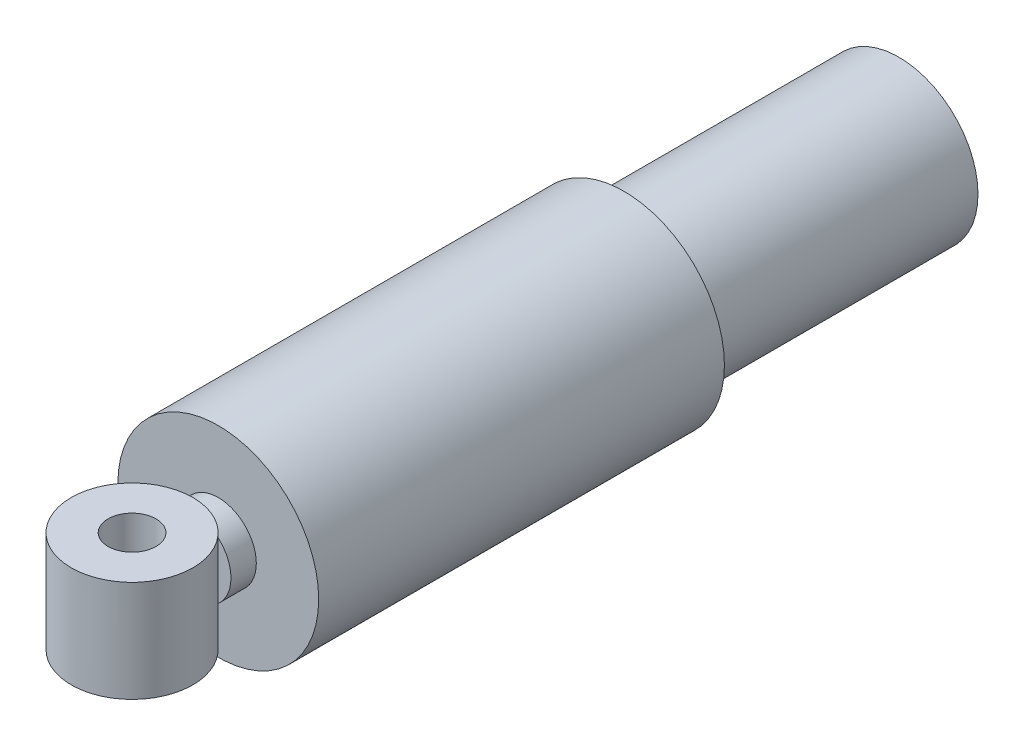
from build123d import *

# Parameters (mm, degrees)
SKETCH1_R           = 19.812
BOSS_EXTRUDE1_DEPTH = 68.834
SKETCH2_R           = 25.146
BOSS_EXTRUDE2_DEPTH = 101.6
SKETCH3_R           = 9.525
BOSS_EXTRUDE3_DEPTH = 6.35
SKETCH5_R           = 15.24
BOSS_EXTRUDE4_DEPTH = 12.7
SKETCH6_R           = 15.24
BOSS_EXTRUDE5_DEPTH = 12.7
SKETCH7_R           = 6.00075
CUT_EXTRUDE1_DEPTH  = 38.846


with BuildPart() as part:
    # Sketch1 → Boss-Extrude1 (new body)
    with BuildSketch(Plane.XY):
        Circle(SKETCH1_R)
    extrude(amount=BOSS_EXTRUDE1_DEPTH)

    # Sketch2 → Boss-Extrude2 (add)
    with BuildSketch(Plane.XY.offset(68.834)):
        Circle(SKETCH2_R)
    extrude(amount=BOSS_EXTRUDE2_DEPTH)

    # Sketch3 → Boss-Extrude3 (add)
    with BuildSketch(Plane.XY.offset(170.434)):
        Circle(SKETCH3_R)
    extrude(amount=BOSS_EXTRUDE3_DEPTH)


with BuildPart() as body_2:
    # Sketch5 → Boss-Extrude4 (new body)
    with BuildSketch(Plane(origin=(0, 0, 0), x_dir=(1, 0, 0), z_dir=(0, 1, 0))):
        with Locations((0, -192.024)):
            Circle(SKETCH5_R)
    extrude(amount=BOSS_EXTRUDE4_DEPTH)

    # Sketch6 → Boss-Extrude5 (add)
    with BuildSketch(Plane.XZ):
        with Locations((0, 192.024)):
            Circle(SKETCH6_R)
    extrude(amount=BOSS_EXTRUDE5_DEPTH)

    # Sketch7 → Cut-Extrude1 (cut, through all)
    with BuildSketch(Plane(origin=(0, 12.7, 0), x_dir=(1, 0, 0), z_dir=(0, 1, 0))):
        with Locations((0, -192.024)):
            Circle(SKETCH7_R)
    extrude(amount=-CUT_EXTRUDE1_DEPTH, mode=Mode.SUBTRACT)


solid = Compound([part.part, body_2.part])
